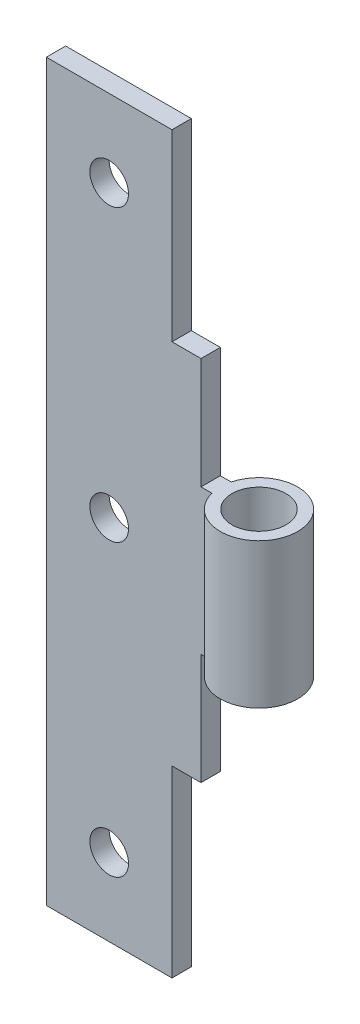
from build123d import *

# Parameters (mm, degrees)
SKETCH1_R           = 1.4
BOSS_EXTRUDE1_DEPTH = 7.5
SKETCH2_W           = 8
SKETCH2_H           = 1
BOSS_EXTRUDE2_DEPTH = 5.75
SKETCH3_W           = 8
SKETCH3_H           = 1
BOSS_EXTRUDE3_DEPTH = 5.75
SKETCH4_W           = 6.5
SKETCH4_H           = 1
BOSS_EXTRUDE4_DEPTH = 9.5
SKETCH5_W           = 6.5
SKETCH5_H           = 1
BOSS_EXTRUDE5_DEPTH = 9.5
CUT_EXTRUDE1_REACH  = 4.5
SKETCH6_R           = 1


with BuildPart() as part:
    # Sketch1 → Boss-Extrude1 (new body)
    with BuildSketch(Plane(origin=(0, 0, 0), x_dir=(1, 0, 0), z_dir=(0, 1, 0))):
        with BuildLine():
            Line((2.313508327, 0.5), (-6.25, 0.5))
            Line((-6.25, 0.5), (-6.25, -0.5))
            Line((-6.25, -0.5), (2.313508327, -0.5))
            ThreePointArc((2.313508327, -0.5), (6.25, 0), (2.313508327, 0.5))
        make_face()
        with Locations((4.25, 0)):
            Circle(SKETCH1_R, mode=Mode.SUBTRACT)
    extrude(amount=BOSS_EXTRUDE1_DEPTH)

    # Sketch2 → Boss-Extrude2 (add)
    with BuildSketch(Plane(origin=(0, 7.5, 0), x_dir=(1, 0, 0), z_dir=(0, 1, 0))):
        with Locations((-2.25, 0)):
            Rectangle(SKETCH2_W, SKETCH2_H)
    extrude(amount=BOSS_EXTRUDE2_DEPTH)

    # Sketch3 → Boss-Extrude3 (add)
    with BuildSketch(Plane.XZ):
        with Locations((-2.25, 0)):
            Rectangle(SKETCH3_W, SKETCH3_H)
    extrude(amount=BOSS_EXTRUDE3_DEPTH)

    # Sketch4 → Boss-Extrude4 (add)
    with BuildSketch(Plane.XZ.offset(5.75)):
        with Locations((-3, 0)):
            Rectangle(SKETCH4_W, SKETCH4_H)
    extrude(amount=BOSS_EXTRUDE4_DEPTH)

    # Sketch5 → Boss-Extrude5 (add)
    with BuildSketch(Plane(origin=(0, 13.25, 0), x_dir=(1, 0, 0), z_dir=(0, 1, 0))):
        with Locations((-3, 0)):
            Rectangle(SKETCH5_W, SKETCH5_H)
    extrude(amount=BOSS_EXTRUDE5_DEPTH)

    # Sketch6 → Cut-Extrude1 (cut, up to next)
    with BuildSketch(Plane.XY.offset(0.5), mode=Mode.PRIVATE) as cut_extrude1_sk1:
        with Locations((-3, 18.75)):
            Circle(SKETCH6_R)
    cut_extrude1_tool1 = extrude(cut_extrude1_sk1.sketch, amount=-CUT_EXTRUDE1_REACH, mode=Mode.PRIVATE) & part.part
    add(cut_extrude1_tool1.solids().sort_by_distance((-3, 18.75, 0.5))[0], mode=Mode.SUBTRACT)
    # Sketch6 → Cut-Extrude1 (cut, up to next)
    with BuildSketch(Plane.XY.offset(0.5), mode=Mode.PRIVATE) as cut_extrude1_sk2:
        with Locations((-3, 3.75)):
            Circle(SKETCH6_R)
    cut_extrude1_tool2 = extrude(cut_extrude1_sk2.sketch, amount=-CUT_EXTRUDE1_REACH, mode=Mode.PRIVATE) & part.part
    add(cut_extrude1_tool2.solids().sort_by_distance((-3, 3.75, 0.5))[0], mode=Mode.SUBTRACT)
    # Sketch6 → Cut-Extrude1 (cut, up to next)
    with BuildSketch(Plane.XY.offset(0.5), mode=Mode.PRIVATE) as cut_extrude1_sk3:
        with Locations((-3, -11.25)):
            Circle(SKETCH6_R)
    cut_extrude1_tool3 = extrude(cut_extrude1_sk3.sketch, amount=-CUT_EXTRUDE1_REACH, mode=Mode.PRIVATE) & part.part
    add(cut_extrude1_tool3.solids().sort_by_distance((-3, -11.25, 0.5))[0], mode=Mode.SUBTRACT)


solid = part.part
